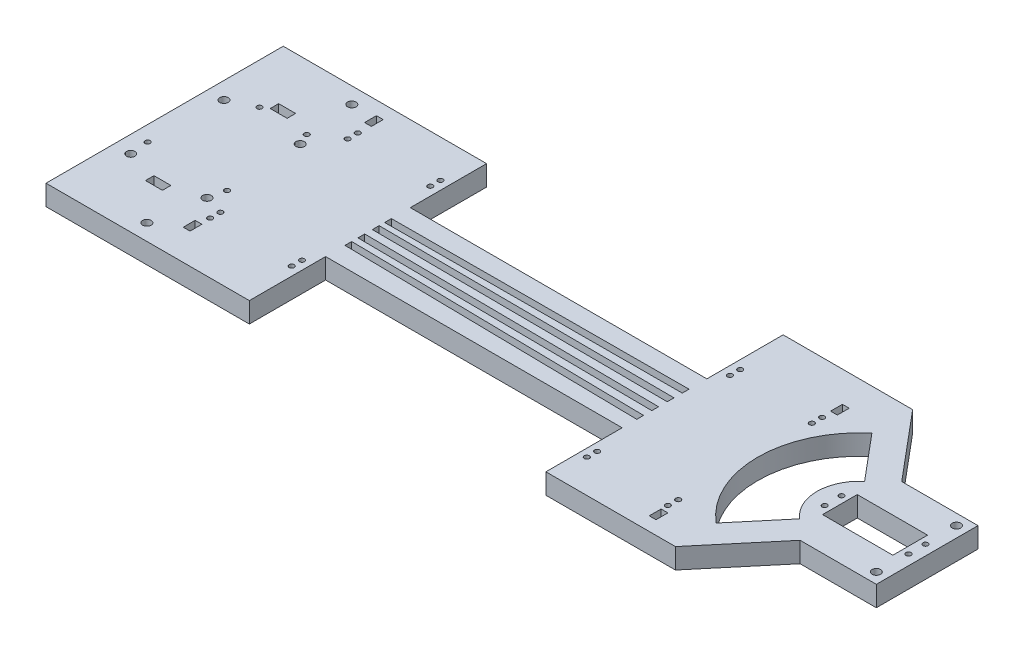
from build123d import *

# Parameters (mm, degrees)
SKETCH1_R           = 1.5
SKETCH1_R_2         = 2.5
SKETCH1_W           = 10
SKETCH1_H           = 5
SKETCH1_W_2         = 4
SKETCH1_H_2         = 7
SKETCH1_W_3         = 41.5
SKETCH1_H_3         = 20.5
BOSS_EXTRUDE1_DEPTH = 12
SKETCH2_R           = 2.5
CUT_EXTRUDE1_DEPTH  = 13


with BuildPart() as part:
    # Sketch1 → Boss-Extrude1 (new body)
    with BuildSketch(Plane(origin=(0, 0, 0), x_dir=(1, 0, 0), z_dir=(0, 1, 0))):
        Polygon((295, 140), (450, 140), (450, 0), (295, 0), (295, 45), (120, 45), (120, 0), (0, 0), (0, 140), (120, 140), (120, 95), (295, 95), align=None)
        with Locations(Location((8.95, 51, 0), (0, 0, 270))):  # turned: the seam where the file's is
            Circle(SKETCH1_R, mode=Mode.SUBTRACT)
        with Locations(Location((57.15, 49.7, 0), (0, 0, 270))):  # turned: the seam where the file's is
            Circle(SKETCH1_R, mode=Mode.SUBTRACT)
        with Locations(Location((24.15, 101.8, 0), (0, 0, 270))):  # turned: the seam where the file's is
            Circle(SKETCH1_R, mode=Mode.SUBTRACT)
        with Locations(Location((52.05, 101.8, 0), (0, 0, 270))):  # turned: the seam where the file's is
            Circle(SKETCH1_R, mode=Mode.SUBTRACT)
        with Locations(Location((50, 130.475, 0), (0, 0, 270))):  # turned: the seam where the file's is
            Circle(SKETCH1_R_2, mode=Mode.SUBTRACT)
        with Locations(Location((50, 9.525, 0), (0, 0, 270))):  # turned: the seam where the file's is
            Circle(SKETCH1_R_2, mode=Mode.SUBTRACT)
        with Locations(Location((10, 95, 0), (0, 0, 270))):  # turned: the seam where the file's is
            Circle(SKETCH1_R_2, mode=Mode.SUBTRACT)
        with Locations(Location((10, 40, 0), (0, 0, 270))):  # turned: the seam where the file's is
            Circle(SKETCH1_R_2, mode=Mode.SUBTRACT)
        with Locations(Location((55, 40, 0), (0, 0, 270))):  # turned: the seam where the file's is
            Circle(SKETCH1_R_2, mode=Mode.SUBTRACT)
        with Locations(Location((55, 95, 0), (0, 0, 270))):  # turned: the seam where the file's is
            Circle(SKETCH1_R_2, mode=Mode.SUBTRACT)
        with Locations(Location((394.5, 75, 0), (0, 0, 270))):  # turned: the seam where the file's is
            Circle(SKETCH1_R, mode=Mode.SUBTRACT)
        with Locations(Location((394.5, 65, 0), (0, 0, 270))):  # turned: the seam where the file's is
            Circle(SKETCH1_R, mode=Mode.SUBTRACT)
        with Locations(Location((444, 75, 0), (0, 0, 270))):  # turned: the seam where the file's is
            Circle(SKETCH1_R, mode=Mode.SUBTRACT)
        with Locations(Location((444, 65, 0), (0, 0, 270))):  # turned: the seam where the file's is
            Circle(SKETCH1_R, mode=Mode.SUBTRACT)
        with Locations(Location((114.940849733, 111.822591207, 0), (0, 0, 270))):  # turned: the seam where the file's is
            Circle(SKETCH1_R, mode=Mode.SUBTRACT)
        with Locations(Location((114.919764018, 117.822591207, 0), (0, 0, 270))):  # turned: the seam where the file's is
            Circle(SKETCH1_R, mode=Mode.SUBTRACT)
        with Locations(Location((66.34114984, 111.651797976, 0), (0, 0, 270))):  # turned: the seam where the file's is
            Circle(SKETCH1_R, mode=Mode.SUBTRACT)
        with Locations(Location((66.320064126, 117.651797976, 0), (0, 0, 270))):  # turned: the seam where the file's is
            Circle(SKETCH1_R, mode=Mode.SUBTRACT)
        with Locations(Location((114.91898341, 36.133817731, 0), (0, 0, 270))):  # turned: the seam where the file's is
            Circle(SKETCH1_R, mode=Mode.SUBTRACT)
        with Locations(Location((114.864297696, 30.133817731, 0), (0, 0, 270))):  # turned: the seam where the file's is
            Circle(SKETCH1_R, mode=Mode.SUBTRACT)
        with Locations(Location((66.266327532, 30.577999595, 0), (0, 0, 270))):  # turned: the seam where the file's is
            Circle(SKETCH1_R, mode=Mode.SUBTRACT)
        with Locations(Location((66.321013247, 36.577999595, 0), (0, 0, 270))):  # turned: the seam where the file's is
            Circle(SKETCH1_R, mode=Mode.SUBTRACT)
        with Locations(Location((300.048791832, 103.567263833, 0), (0, 0, 270))):  # turned: the seam where the file's is
            Circle(SKETCH1_R, mode=Mode.SUBTRACT)
        with Locations(Location((300.082906118, 109.567263833, 0), (0, 0, 270))):  # turned: the seam where the file's is
            Circle(SKETCH1_R, mode=Mode.SUBTRACT)
        with Locations(Location((348.682120582, 109.290942585, 0), (0, 0, 270))):  # turned: the seam where the file's is
            Circle(SKETCH1_R, mode=Mode.SUBTRACT)
        with Locations(Location((348.648006297, 103.290942585, 0), (0, 0, 270))):  # turned: the seam where the file's is
            Circle(SKETCH1_R, mode=Mode.SUBTRACT)
        with Locations(Location((299.691143962, 25.55274586, 0), (0, 0, 270))):  # turned: the seam where the file's is
            Circle(SKETCH1_R, mode=Mode.SUBTRACT)
        with Locations(Location((299.595658248, 19.55274586, 0), (0, 0, 270))):  # turned: the seam where the file's is
            Circle(SKETCH1_R, mode=Mode.SUBTRACT)
        with Locations(Location((348.284990804, 24.779409497, 0), (0, 0, 270))):  # turned: the seam where the file's is
            Circle(SKETCH1_R, mode=Mode.SUBTRACT)
        with Locations(Location((348.18950509, 18.779409497, 0), (0, 0, 270))):  # turned: the seam where the file's is
            Circle(SKETCH1_R, mode=Mode.SUBTRACT)
        Polygon((120, 83.84), (295, 84.455), (295, 80.455), (120, 79.84), align=None, mode=Mode.SUBTRACT)
        Polygon((120, 76.59), (295, 75.595), (295, 71.595), (120, 72.59), align=None, mode=Mode.SUBTRACT)
        Polygon((120, 68.09), (295, 66.495), (295, 62.495), (120, 64.09), align=None, mode=Mode.SUBTRACT)
        Polygon((120, 60.42), (295, 57.635), (295, 53.635), (120, 56.42), align=None, mode=Mode.SUBTRACT)
        with Locations((33, 106.8)):
            Rectangle(SKETCH1_W, SKETCH1_H, mode=Mode.SUBTRACT)
        with Locations((33, 33.2)):
            Rectangle(SKETCH1_W, SKETCH1_H, mode=Mode.SUBTRACT)
        with Locations((65, 128.5)):
            Rectangle(SKETCH1_W_2, SKETCH1_H_2, mode=Mode.SUBTRACT)
        with Locations((65, 21.5)):
            Rectangle(SKETCH1_W_2, SKETCH1_H_2, mode=Mode.SUBTRACT)
        with Locations((419.25, 70)):
            Rectangle(SKETCH1_W_3, SKETCH1_H_3, mode=Mode.SUBTRACT)
        with BuildLine():
            Line((393.930309758, 50.848888922), (371.432743419, 24.037333413))
            ThreePointArc((371.432743419, 24.037333413), (350, 70), (371.432743419, 115.962666587))
            Line((371.432743419, 115.962666587), (393.930309758, 89.151111078))
            ThreePointArc((393.930309758, 89.151111078), (385, 70), (393.930309758, 50.848888922))
        make_face(mode=Mode.SUBTRACT)
        with Locations((350, 118.5)):
            Rectangle(SKETCH1_W_2, SKETCH1_H_2, mode=Mode.SUBTRACT)
        with Locations((350, 11.5)):
            Rectangle(SKETCH1_W_2, SKETCH1_H_2, mode=Mode.SUBTRACT)
    extrude(amount=BOSS_EXTRUDE1_DEPTH)

    # Sketch2 → Cut-Extrude1 (cut, through all)
    with BuildSketch(Plane(origin=(0, 12, 0), x_dir=(1, 0, 0), z_dir=(0, 1, 0))):
        with Locations(Location((443.65, 93.65, 0), (0, 0, 270))):  # turned: the seam where the file's is
            Circle(SKETCH2_R)
        with Locations(Location((443.65, 46.35, 0), (0, 0, 270))):  # turned: the seam where the file's is
            Circle(SKETCH2_R)
        Polygon((371.432743419, 140), (404.996728666, 100), (450, 100), (450, 140), align=None)
        Polygon((371.432743419, 0), (404.996728666, 40), (450, 40), (450, 0), align=None)
    extrude(amount=-CUT_EXTRUDE1_DEPTH, mode=Mode.SUBTRACT)


solid = part.part
